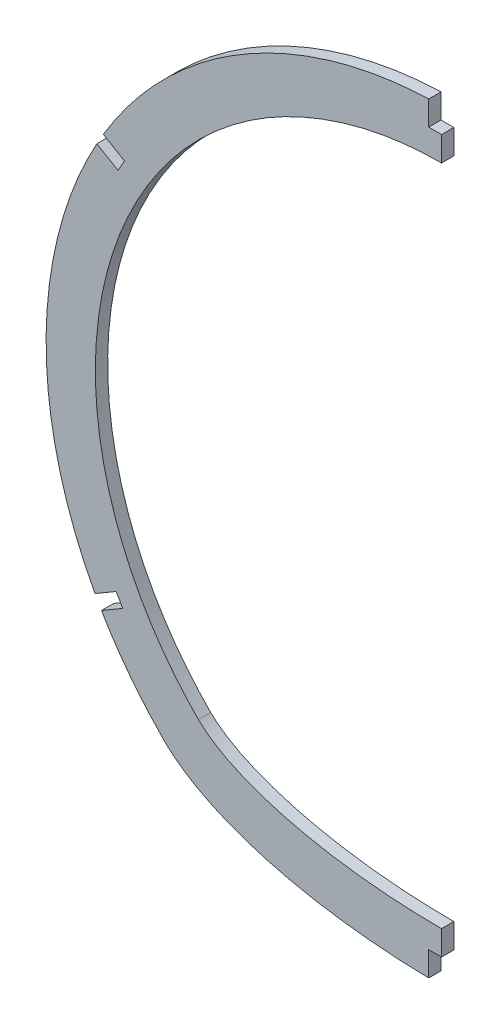
from build123d import *

# Parameters (mm, degrees)
BOSS_EXTRUDE1_DEPTH = 3.175
SKETCH3_W           = 129.389558459
SKETCH3_H           = 294.720660933
CUT_EXTRUDE1_DEPTH  = 102.960845412
SKETCH4_W           = 3.302
SKETCH4_H           = 12.7
CUT_EXTRUDE2_DEPTH  = 4.1750001


with BuildPart() as part:
    # Sketch2 → Boss-Extrude1 (new body)
    with BuildSketch(Plane.XY):
        with BuildLine():
            add(Edge.make_bspline(
                [(-71.677392112, -72.91043434), (-72.109242456, -72.4766599), (-72.972872043, -71.593614958), (-74.469591152, -70.002616718), (-75.837182996, -68.488043391), (-77.186084408, -66.931897067), (-78.515677479, -65.334729876), (-79.824432739, -63.69624614), (-81.54760822, -61.446428575), (-83.64161213, -58.529673548), (-85.629566809, -55.501403393), (-87.162218254, -52.997335562), (-88.285911427, -51.070131488), (-90.114728738, -47.772436811), (-92.549922179, -42.891387424), (-95.3516338, -36.175158441), (-97.806777615, -28.854790192), (-99.416568113, -22.492651102), (-100.484378106, -16.973479224), (-101.217383692, -12.115821661), (-101.805900705, -6.108471449), (-102.055561509, 1.055644647), (-101.63758347, 11.916616183), (-99.581715265, 24.703392789), (-94.947787628, 39.477591596), (-88.656512854, 52.708120751), (-80.043367163, 65.554146484), (-69.871244821, 76.755385293), (-58.636991603, 85.914826096), (-47.202028885, 92.898966836), (-35.790499648, 98.052224226), (-24.000842482, 101.716725174), (-12.029496563, 103.894248368), (-3.656941748, 104.395312689), (0.99110515, 104.372307848), (2.644688984, 104.347784008), (5.295920706, 104.255895368), (8.944129249, 104.002381094), (12.923536456, 103.566176285), (16.897932891, 102.969160213), (20.860675893, 102.210568115), (24.80503533, 101.28991654), (28.724197829, 100.207008268), (32.611281662, 98.961940132), (36.459348765, 97.555109249), (39.942943882, 96.118550993), (42.44327487, 94.981609399), (43.99462248, 94.237634049), (44.922549304, 93.78091779), (45.846607961, 93.314294304), (46.766722746, 92.837849145), (47.682656642, 92.351383169), (48.561810847, 91.873519084), (49.188310006, 91.524412896), (49.500915025, 91.348034768)],
                knots=[0, 0, 0, 0, 0.006795371, 0.013653749, 0.020575359, 0.027560428, 0.034609183, 0.041721853, 0.048898669, 0.063445664, 0.078252032, 0.085753069, 0.093319659, 0.100952039, 0.124124286, 0.148784986, 0.174947707, 0.20262677, 0.215493637, 0.232144402, 0.252599943, 0.276885796, 0.305032091, 0.363115877, 0.408011314, 0.462235121, 0.511576331, 0.564908162, 0.615597651, 0.658548959, 0.700915758, 0.742691235, 0.783870362, 0.824449909, 0.827808956, 0.831171349, 0.841278604, 0.854801757, 0.868378359, 0.882008332, 0.895691582, 0.909427999, 0.923217451, 0.937059793, 0.95095486, 0.964902468, 0.975397534, 0.978902417, 0.982410558, 0.985921952, 0.989436598, 0.99295449, 0.996475625, 1, 1, 1, 1], degree=3))
            add(Edge.make_bspline(
                [(49.500915025, 91.348034768), (49.872005924, 91.138482333), (50.241810712, 90.926750039), (50.610303013, 90.712853821)],
                knots=[0, 0, 0, 0, 1, 1, 1, 1], degree=3))
            add(Edge.make_bspline(
                [(50.610303013, 90.712853821), (51.128442093, 90.411846037), (52.167202685, 89.796039228), (53.932536969, 88.703576387), (55.579762788, 87.638711627), (57.218137155, 86.533145805), (58.847026669, 85.387425363), (60.465187486, 84.201108463), (62.61485058, 82.559008476), (65.268683437, 80.403244909), (68.38020159, 77.661045558), (71.420405526, 74.753669295), (74.379227375, 71.68115848), (77.246352549, 68.444125522), (79.542797672, 65.619898893), (81.324264236, 63.280297585), (82.635173495, 61.479754257), (83.915139631, 59.639466174), (85.682600666, 56.976700672), (87.896856718, 53.369477174), (90.462597049, 48.676901727), (92.889220315, 43.626105667), (95.132677705, 38.215723181), (97.146538959, 32.44823322), (98.88212407, 26.330630408), (100.289240179, 19.875099059), (101.25863273, 13.473856941), (101.817336128, 7.24671143), (102.015185645, 1.305015561), (101.87858065, -4.624237286), (101.39263307, -10.734726225), (100.537146292, -16.867570025), (99.329398352, -22.86381348), (97.893600846, -28.372193875), (96.656960211, -32.269847721), (95.785564151, -34.744415114), (95.0459628, -36.764317914), (93.953188789, -39.535816997), (92.43580554, -43.007047711), (90.821696456, -46.36490671), (89.118620831, -49.608230444), (87.334164726, -52.736260206), (85.475724639, -55.748623833), (83.55049497, -58.64531039), (81.56545684, -61.42664709), (79.307705413, -64.380683017), (77.436977348, -66.647222523), (76.007346494, -68.288860963), (75.29509586, -69.089727056), (74.579038656, -69.87823774), (73.859443089, -70.654502436), (73.136338858, -71.418398838), (72.317504882, -72.264736672), (71.891235125, -72.69667798), (71.678426975, -72.91043429)],
                knots=[0, 0, 0, 0, 0.010157109, 0.020393378, 0.030708694, 0.04110294, 0.051575992, 0.062127721, 0.072757993, 0.094253595, 0.116061609, 0.138180754, 0.160609666, 0.183346893, 0.206390897, 0.218027437, 0.229740057, 0.241528542, 0.253392669, 0.280162256, 0.30828042, 0.337739229, 0.368530108, 0.400643849, 0.434070605, 0.468799897, 0.504820602, 0.536144777, 0.567394405, 0.598569553, 0.629670285, 0.664058743, 0.696204476, 0.726123241, 0.753829745, 0.760691378, 0.767515904, 0.787767528, 0.807687634, 0.827278023, 0.846540474, 0.865476741, 0.88408856, 0.902377642, 0.920345676, 0.937994331, 0.961031903, 0.966703489, 0.972340071, 0.97794171, 0.983508463, 0.989040391, 0.99453755, 1, 1, 1, 1], degree=3))
            add(Edge.make_bspline(
                [(71.678426975, -72.91043429), (46.359928794, -98.341734638), (-46.358893881, -98.341734638), (-71.677392112, -72.91043434)],
                knots=[0, 0, 0, 0, 1, 1, 1, 1], degree=3, weights=[1, 1, 1, 1]))
        make_face()
        with BuildLine():
            add(Edge.make_bspline(
                [(-62.677197057, -63.950161522), (-62.895509204, -63.730876692), (-63.321725733, -63.298342375), (-64.002059554, -62.592101669), (-64.753829554, -61.794622516), (-65.703931611, -60.764569773), (-66.804574903, -59.527416198), (-68.556788175, -57.468052236), (-70.648178443, -54.835505477), (-73.811350461, -50.469012961), (-77.394544541, -44.756057433), (-82.302878117, -35.13540616), (-86.810757895, -22.360038108), (-90.354277409, -0.967371821), (-87.649941962, 26.350088977), (-73.333390238, 55.972118358), (-49.623996274, 78.708841275), (-24.487235723, 89.383519301), (-3.090994932, 92.115890306), (13.038963103, 91.197514401), (26.120286031, 87.996586306), (34.879374941, 84.524845656), (39.102105625, 82.510352052), (41.214271269, 81.410816796), (42.347028641, 80.797644792), (42.959233617, 80.456937494), (43.258169219, 80.288282027)],
                knots=[0, 0, 0, 0, 0.003906217, 0.007812434, 0.01171865, 0.015624867, 0.023437301, 0.031249734, 0.046874602, 0.062499469, 0.093749203, 0.124998938, 0.187498407, 0.249997875, 0.374996813, 0.499995751, 0.624994688, 0.749993626, 0.812493095, 0.874992564, 0.937492033, 0.968741767, 0.984366634, 0.992179068, 0.996085285, 0.999991501, 0.999991501, 0.999991501, 0.999991501], degree=3))
            add(Edge.make_bspline(
                [(43.258169219, 80.288282027), (43.339663738, 80.24226006), (43.502520945, 80.149972739), (43.746371392, 80.01083423), (43.989796594, 79.870982545), (44.151786326, 79.777278604), (44.232713854, 79.73030574)],
                knots=[0.002022438, 0.002022438, 0.002022438, 0.002022438, 0.251013535, 0.500004632, 0.748995729, 0.997986827, 0.997986827, 0.997986827, 0.997986827], degree=3))
            add(Edge.make_bspline(
                [(44.232713854, 79.73030574), (44.58444416, 79.525959484), (45.259622085, 79.127643656), (46.415361761, 78.422292298), (47.573803007, 77.692810893), (49.007921659, 76.758403592), (50.804832808, 75.530634538), (53.607223777, 73.493209173), (57.003409969, 70.790302329), (64.764138566, 63.842060668), (74.853642347, 51.769295456), (84.311822541, 33.000711524), (89.302574517, 12.581832114), (89.594071681, -8.463887057), (85.167338267, -29.022546245), (78.471156755, -43.288686452), (72.737789819, -52.004533398), (70.145497848, -55.492337454), (67.954788222, -58.18874646), (66.537169113, -59.834423786), (65.376799992, -61.124092609), (64.636118066, -61.923784826), (64.04885936, -62.544039678), (63.540759488, -63.072130947), (63.065749199, -63.559376825), (62.8132246, -63.814567336), (62.678231924, -63.950161468)],
                knots=[1.4601e-05, 1.4601e-05, 1.4601e-05, 1.4601e-05, 0.007826987, 0.015639373, 0.023451759, 0.031264145, 0.046888916, 0.062513688, 0.093763232, 0.125012776, 0.250010951, 0.375009125, 0.5000073, 0.625005475, 0.75000365, 0.875001825, 0.906251369, 0.937500913, 0.953125684, 0.968750456, 0.976562842, 0.984375228, 0.988281421, 0.992187614, 0.996093807, 1, 1, 1, 1], degree=3))
            add(Edge.make_bspline(
                [(62.678231924, -63.950161468), (62.442110433, -64.187331736), (61.973465348, -64.632177633), (60.848308103, -65.594894105), (59.178943877, -66.825880953), (56.737455869, -68.325151322), (52.942333804, -70.28884928), (47.260951473, -72.599488515), (39.221466424, -74.977986937), (30.229046438, -76.880115217), (17.304785319, -78.721740765), (0.000517457, -79.658688067), (-17.303750406, -78.721740765), (-30.228011525, -76.880115217), (-39.22043151, -74.977986937), (-47.25991656, -72.599488515), (-52.941298891, -70.28884928), (-56.736420955, -68.325151322), (-59.177908963, -66.825880953), (-60.84727319, -65.594894105), (-61.972430435, -64.632177633), (-62.441075519, -64.187331736), (-62.677197057, -63.950161522)],
                knots=[0, 0, 0, 0, 0.015625, 0.03125, 0.0625, 0.09375, 0.125, 0.1875, 0.25, 0.3125, 0.375, 0.5, 0.625, 0.6875, 0.75, 0.8125, 0.875, 0.90625, 0.9375, 0.96875, 0.984375, 1, 1, 1, 1], degree=3))
        make_face(mode=Mode.SUBTRACT)
    extrude(amount=-BOSS_EXTRUDE1_DEPTH)

    # Sketch3 → Cut-Extrude1 (cut, through all)
    with BuildSketch(Plane(origin=(0, 0, 0), x_dir=(0, 0, -1), z_dir=(1, 0, 0))):
        with Locations((3.684090068, 10.698040846)):
            Rectangle(SKETCH3_W, SKETCH3_H)
    extrude(amount=CUT_EXTRUDE1_DEPTH, mode=Mode.SUBTRACT)

    # Sketch4 → Cut-Extrude2 (cut, through all)
    with BuildSketch(Plane(origin=(0, 0, -3.175), x_dir=(-1, 0, 0), z_dir=(0, 0, -1))):
        with Locations((1.651, 104.37520294)):
            Rectangle(SKETCH4_W, SKETCH4_H)
        Polygon((81.722062158, 51.245774998), (83.431923254, 48.332253027), (94.385013368, 54.760302263), (92.675152271, 57.673824233), align=None)
        Polygon((82.193637427, -48.868559709), (83.903498529, -45.955037742), (94.85658863, -52.383086998), (93.146727528, -55.296608965), align=None)
        with Locations((1.651, -91.983909146)):
            Rectangle(SKETCH4_W, SKETCH4_H)
    extrude(amount=-CUT_EXTRUDE2_DEPTH, mode=Mode.SUBTRACT)


solid = part.part
